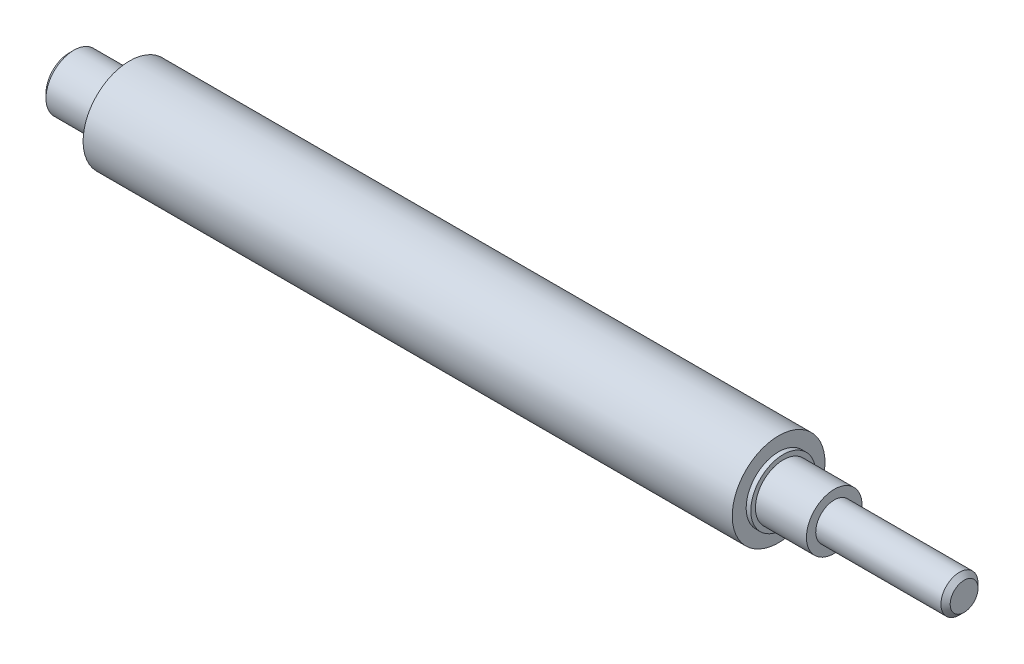
from build123d import *

# Parameters (mm, degrees)
CHAMFER1_SIZE = 0.5


with BuildPart() as part:
    # Sketch1 → Revolve1 (revolve)
    with BuildSketch(Plane.XY):
        Polygon((0, 0), (0, 3), (6, 3), (6, 3.5), (6.5, 3.5), (6.5, 5), (76.5, 5), (76.5, 3.5), (77, 3.5), (77, 3), (82.5, 3), (82.5, 2), (96.5, 2), (96.5, 0), align=None)
    revolve(axis=Axis((96.5, 0, 0), (-1, 0, 0)))

    # Chamfer1
    chamfer1_edges = [part.edges().sort_by_distance(p)[0] for p in [
        (0, -3, 0),
        (96.5, -2, 0),
    ]]
    chamfer(chamfer1_edges, length=CHAMFER1_SIZE)


solid = part.part
